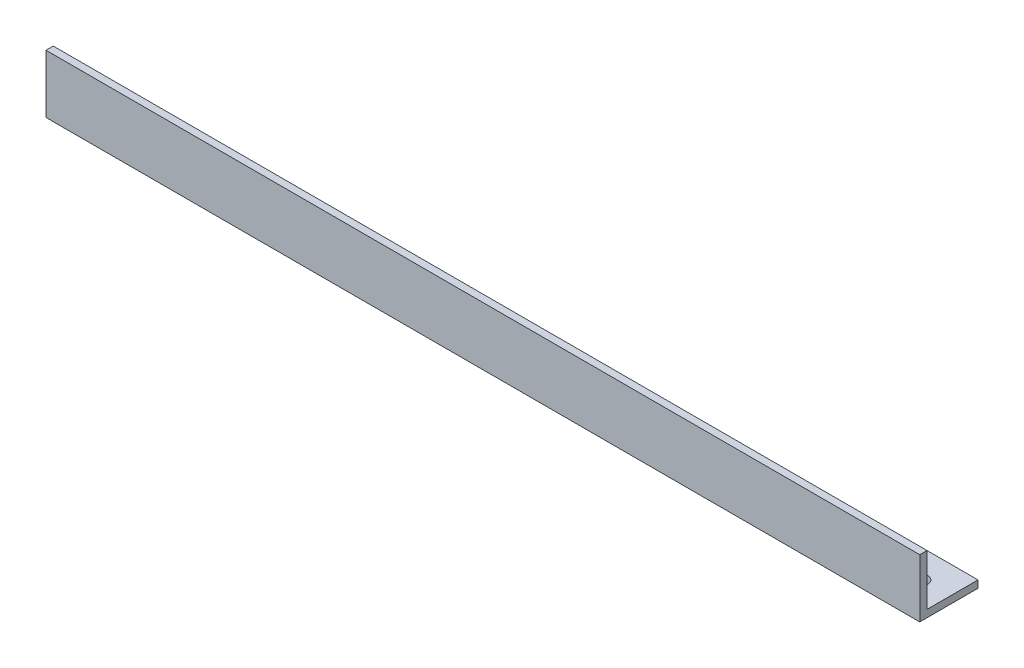
from build123d import *

# Parameters (mm, degrees)
BOSS_EXTRUDE1_DEPTH = 381
CUT_EXTRUDE1_REACH  = 27.4
SKETCH2_R           = 3.429


with BuildPart() as part:
    # Sketch1 → Boss-Extrude1 (new body)
    with BuildSketch(Plane(origin=(0, 0, 0), x_dir=(0, 0, -1), z_dir=(1, 0, 0))):
        Polygon((0, 0), (25.4, 0), (25.4, 3.175), (3.175, 3.175), (3.175, 25.4), (0, 25.4), align=None)
    extrude(amount=BOSS_EXTRUDE1_DEPTH)

    # Sketch2 → Cut-Extrude1 (cut, up to next)
    with BuildSketch(Plane.XZ, mode=Mode.PRIVATE) as cut_extrude1_sk1:
        with Locations((73.66, -12.7)):
            Circle(SKETCH2_R)
    cut_extrude1_tool1 = extrude(cut_extrude1_sk1.sketch, amount=-CUT_EXTRUDE1_REACH, mode=Mode.PRIVATE) & part.part
    add(cut_extrude1_tool1.solids().sort_by_distance((73.66, 0, -12.7))[0], mode=Mode.SUBTRACT)
    # Sketch2 → Cut-Extrude1 (cut, up to next)
    with BuildSketch(Plane.XZ, mode=Mode.PRIVATE) as cut_extrude1_sk2:
        with Locations((368.3, -12.7)):
            Circle(SKETCH2_R)
    cut_extrude1_tool2 = extrude(cut_extrude1_sk2.sketch, amount=-CUT_EXTRUDE1_REACH, mode=Mode.PRIVATE) & part.part
    add(cut_extrude1_tool2.solids().sort_by_distance((368.3, 0, -12.7))[0], mode=Mode.SUBTRACT)
    # Sketch2 → Cut-Extrude1 (cut, up to next)
    with BuildSketch(Plane.XZ, mode=Mode.PRIVATE) as cut_extrude1_sk3:
        with Locations((19.05, -12.7)):
            Circle(SKETCH2_R)
    cut_extrude1_tool3 = extrude(cut_extrude1_sk3.sketch, amount=-CUT_EXTRUDE1_REACH, mode=Mode.PRIVATE) & part.part
    add(cut_extrude1_tool3.solids().sort_by_distance((19.05, 0, -12.7))[0], mode=Mode.SUBTRACT)


solid = part.part
